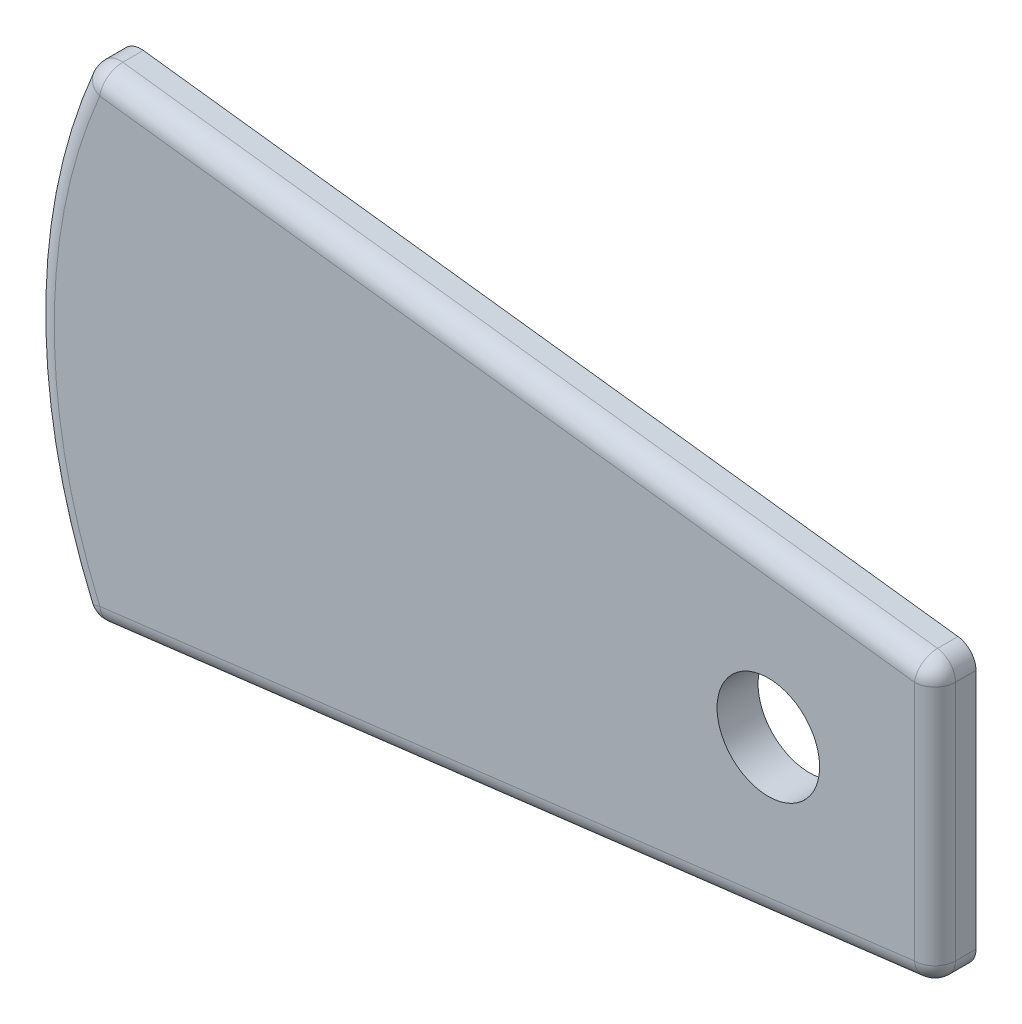
from build123d import *

# Parameters (mm, degrees)
BOSS_EXTRUDE1_DEPTH = 2
FILLET1_R           = 1
FILLET2_R           = 1
SKETCH2_R           = 2.5
CUT_EXTRUDE2_DEPTH  = 2


with BuildPart() as part:
    # Sketch1 → Boss-Extrude1 (new body)
    with BuildSketch(Plane.XY):
        with BuildLine():
            Line((-31.873882869, 46.769006648), (-31.873882869, 33.230993352))
            Line((-31.873882869, 33.230993352), (-73.208494435, 28.145662592))
            ThreePointArc((-73.208494435, 28.145662592), (-75.8185442, 40), (-73.208494435, 51.854337408))
            Line((-73.208494435, 51.854337408), (-31.873882869, 46.769006648))
        make_face()
    extrude(amount=BOSS_EXTRUDE1_DEPTH)

    # Fillet1
    fillet1_edges = [part.edges().sort_by_distance(p)[0] for p in [
        (-73.208494435, 51.854337408, 1),
        (-31.873882869, 46.769006648, 1),
        (-31.873882869, 33.230993352, 1),
        (-73.208494435, 28.145662592, 1),
    ]]
    fillet(fillet1_edges, radius=FILLET1_R)

    # Fillet2
    fillet2_edges = [part.edges().sort_by_distance(p)[0] for p in [
        (-52.613347795, 30.679450349, 2),
        (-75.8185442, 40, 2),
        (-31.873882869, 40, 2),
        (-52.613347795, 49.320549651, 2),
        (-32.124847572, 33.452974438, 2),
        (-32.124847572, 46.547025562, 2),
        (-73.094606247, 51.638989358, 2),
        (-73.094606247, 28.361010642, 2),
    ]]
    fillet(fillet2_edges, radius=FILLET2_R)

    # Sketch2 → Cut-Extrude2 (cut)
    with BuildSketch(Plane.XY.offset(2)):
        with Locations((-40, 40)):
            Circle(SKETCH2_R)
    extrude(amount=-CUT_EXTRUDE2_DEPTH, mode=Mode.SUBTRACT)


solid = part.part
